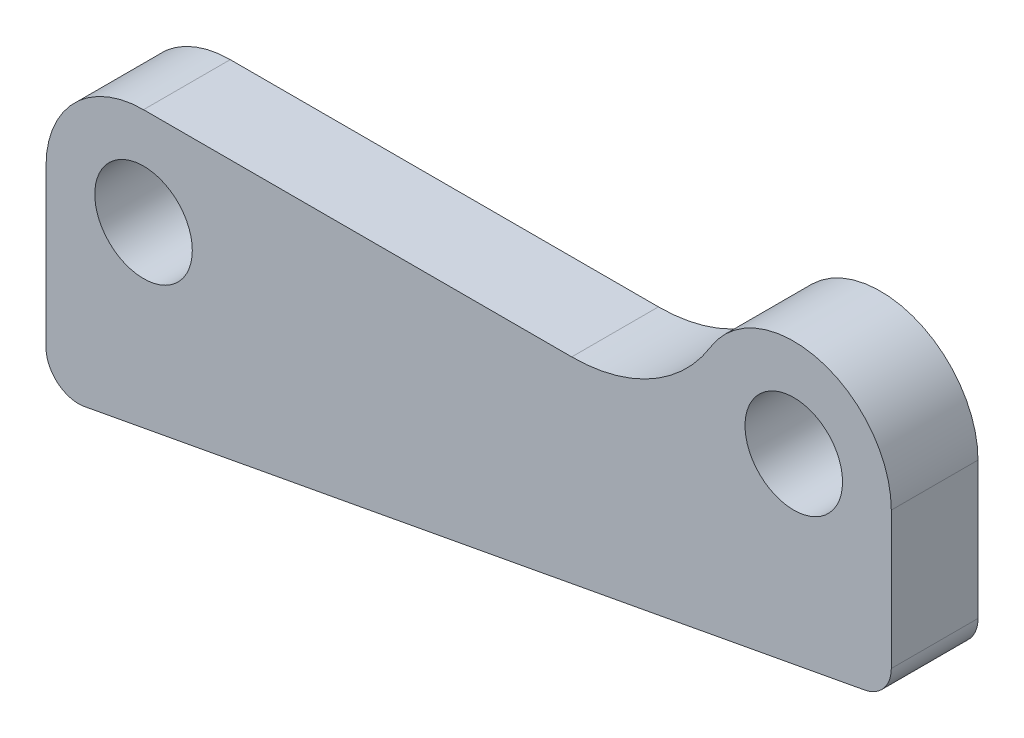
from build123d import *

# Parameters (mm, degrees)
SKETCH1_R      = 4.5
EXTRUDE1_DEPTH = 8


with BuildPart() as part:
    # Sketch1 → Extrude1 (new body)
    with BuildSketch(Plane.XY):
        with BuildLine():
            Line((-9, 0), (-9, -14.5))
            ThreePointArc((-9, -14.5), (-7.918317006, -16.806525496), (-5.453293424, -17.449764723))
            Line((-5.453293424, -17.449764723), (66.546706576, -4.105353488))
            ThreePointArc((66.546706576, -4.105353488), (68.306525496, -3.073905771), (69, -1.155588765))
            Line((69, -1.155588765), (69, 11.5))
            ThreePointArc((69, 11.5), (62.434509272, 20.164477169), (52.317074532, 16.1875))
            ThreePointArc((52.317074532, 16.1875), (46.854286329, 10.91971904), (39.512198751, 9))
            Line((39.512198751, 9), (0, 9))
            ThreePointArc((0, 9), (-6.363961031, 6.363961031), (-9, 0))
        make_face()
        Circle(SKETCH1_R, mode=Mode.SUBTRACT)
        with Locations((60, 11.5)):
            Circle(SKETCH1_R, mode=Mode.SUBTRACT)
    extrude(amount=EXTRUDE1_DEPTH)


solid = part.part
